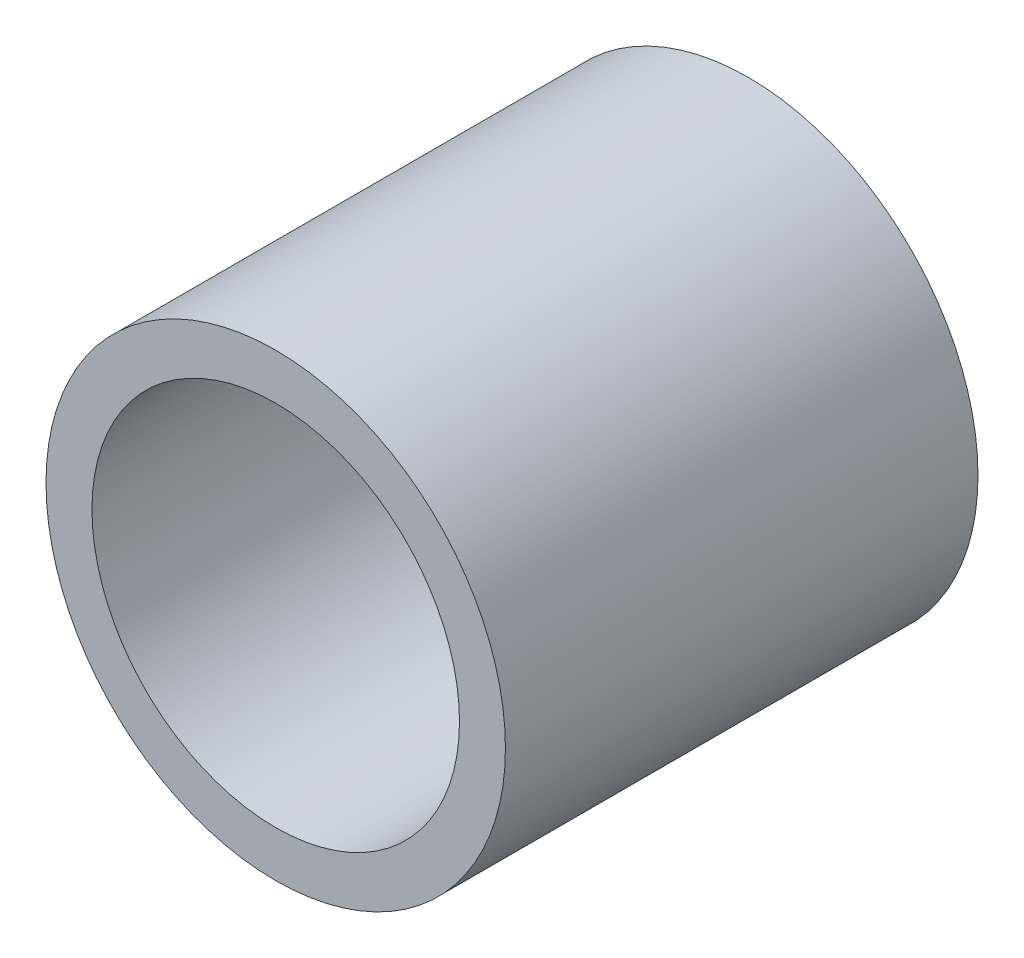
from build123d import *

# Parameters (mm, degrees)
SKETCH2_R           = 17.5
SKETCH2_R_2         = 14
BOSS_EXTRUDE1_DEPTH = 36


with BuildPart() as part:
    # Sketch2 → Boss-Extrude1 (new body)
    with BuildSketch(Plane.XY):
        Circle(SKETCH2_R)
        Circle(SKETCH2_R_2, mode=Mode.SUBTRACT)
    extrude(amount=BOSS_EXTRUDE1_DEPTH)


solid = part.part
